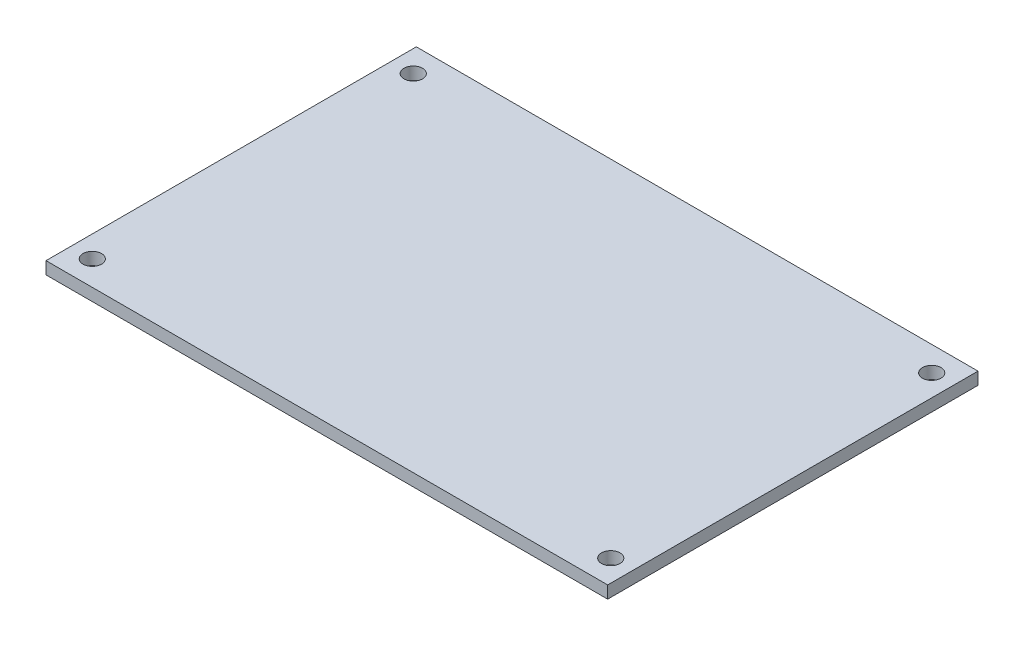
from build123d import *

# Parameters (mm, degrees)
SKETCH_2_W          = 91
SKETCH_2_H          = 60
EXTRUDE_1_DEPTH     = 2
SKETCH_3_R          = 1.5
CUT_EXTRUDE_1_DEPTH = 2


with BuildPart() as part:
    # 草图2 → 凸台-拉伸1 (new body)
    with BuildSketch(Plane(origin=(0, 0, 0), x_dir=(1, 0, 0), z_dir=(0, 1, 0))):
        Rectangle(SKETCH_2_W, SKETCH_2_H)
    extrude(amount=EXTRUDE_1_DEPTH)

    # 草图3 → 切除-拉伸1 (cut)
    with BuildSketch(Plane(origin=(0, 2, 0), x_dir=(1, 0, 0), z_dir=(0, 1, 0))):
        with Locations((-42, 26)):
            Circle(SKETCH_3_R)
        with Locations((42, 26)):
            Circle(SKETCH_3_R)
        with Locations((-42, -26)):
            Circle(SKETCH_3_R)
        with Locations((42, -26)):
            Circle(SKETCH_3_R)
    extrude(amount=-CUT_EXTRUDE_1_DEPTH, mode=Mode.SUBTRACT)


solid = part.part
